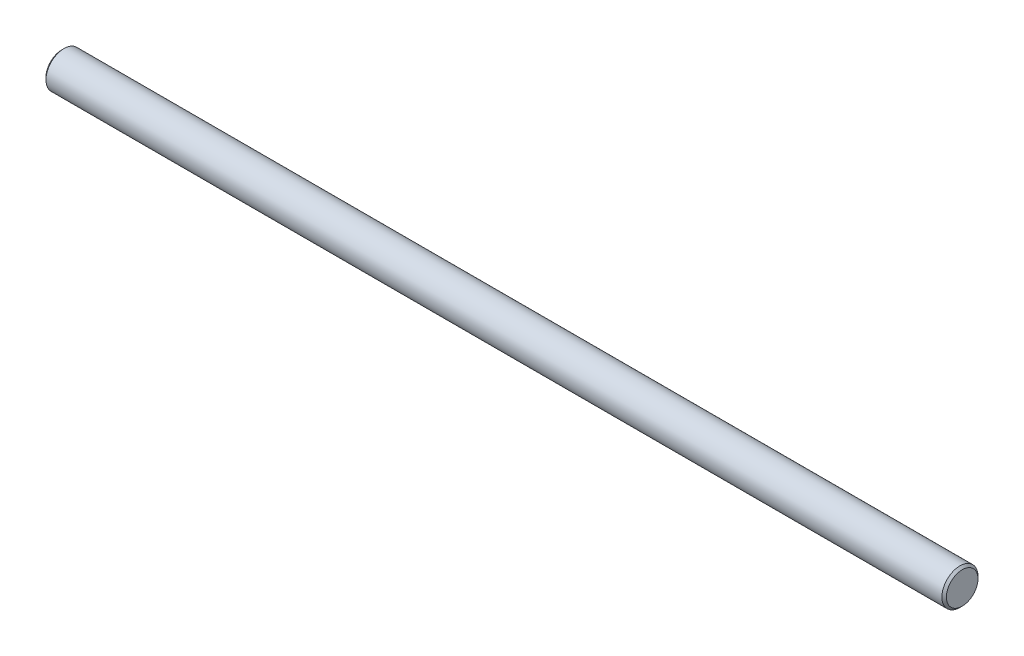
from build123d import *

# Parameters (mm, degrees)
SKETCH1_R           = 4
BOSS_EXTRUDE1_DEPTH = 199.5
CHAMFER1_SIZE       = 0.5


with BuildPart() as part:
    # Sketch1 → Boss-Extrude1 (new body)
    with BuildSketch(Plane(origin=(0, 0, 0), x_dir=(0, 0, -1), z_dir=(1, 0, 0))):
        Circle(SKETCH1_R)
    extrude(amount=BOSS_EXTRUDE1_DEPTH)

    # Chamfer1
    chamfer1_edges = [part.edges().sort_by_distance(p)[0] for p in [
        (0, 0, 4),
        (199.5, 0, 4),
    ]]
    chamfer(chamfer1_edges, length=CHAMFER1_SIZE)


solid = part.part
